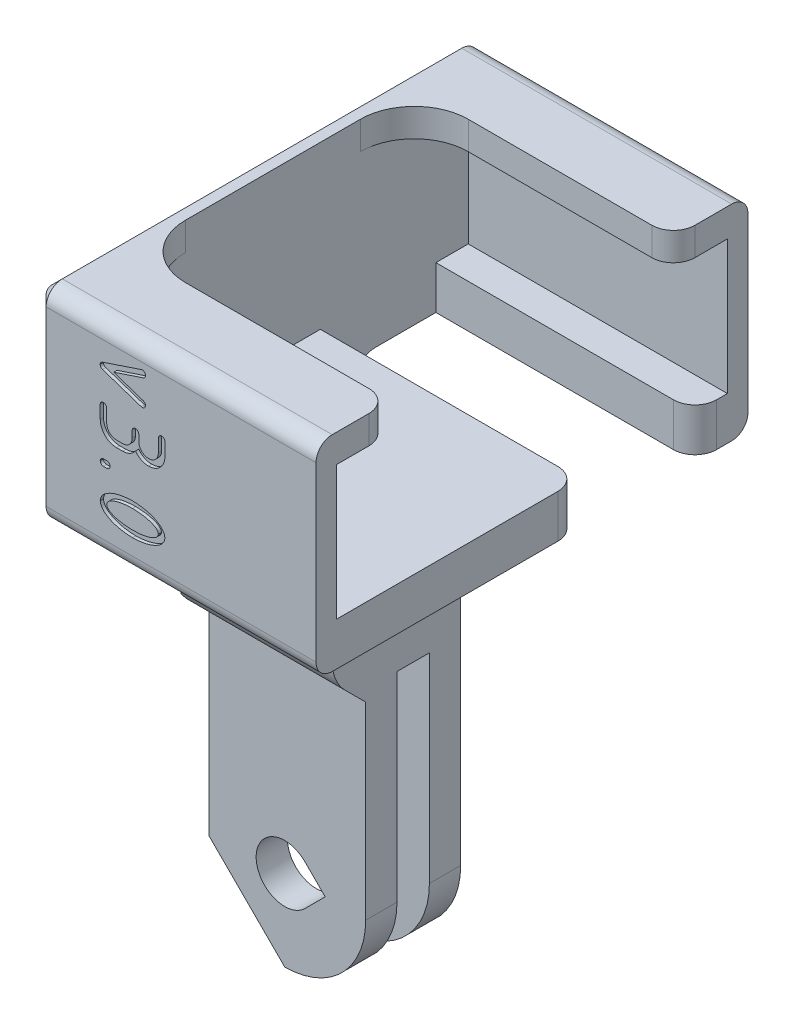
from build123d import *

# Parameters (mm, degrees)
SKETCH1_R                 = 2.65
BOSS_FINGERS_DEPTH        = 7.5
SKETCH2_W                 = 3
SKETCH2_H                 = 25
CUT_FINGERS_DEPTH         = 16
CUT_OVERHANG_DEPTH        = 12.9
CHAMF_GP_WEB_SIZE         = 1
CUT_GOPRO_TEARDROP_DEPTH  = 12.9
CHAMF_GP_BASE_SIZE        = 0.5
SKETCH3_W                 = 40
SKETCH3_H                 = 19
BOSS_BLOCK_DEPTH          = 26
FILLET5_R                 = 2
CUT_CAMERA_POCKET_DEPTH   = 24
SKETCH5_W                 = 24
SKETCH5_H                 = 10.7
CUT_CABLE_EXIT_DEPTH      = 15
CUT_CABLE_EXIT_DEPTH_BACK = 4
FILLET_OUTSIDE_VERT_R     = 1.5
FILLET_CAM_TOP_R          = 2
CHAMF_CAM_BASE_SIZE       = 1
FILLET_CAM_FRONT_R        = 5
FILLET6_R                 = 4
VERSION_NUMBER_DEPTH      = 0.3


with BuildPart() as part:
    # Sketch1 → boss fingers (new body, symmetric)
    with BuildSketch(Plane.XY):
        with BuildLine():
            Line((-7.5, 0), (-7.5, 32.5))
            Line((-7.5, 32.5), (7.5, 32.5))
            Line((7.5, 32.5), (7.5, 0))
            ThreePointArc((7.5, 0), (0, -7.5), (-7.5, 0))
        make_face()
        Circle(SKETCH1_R, mode=Mode.SUBTRACT)
    extrude(amount=BOSS_FINGERS_DEPTH, both=True)

    # Sketch2 → cut fingers (cut, through all)
    with BuildSketch(Plane.ZY.offset(7.5)):
        Polygon((-7.5, -7.5), (-4.4, -7.5), (-4.4, 17.5), (-7.5, 20.6), (-7.5, 17.5), align=None)
        with Locations((0, 5)):
            Rectangle(SKETCH2_W, SKETCH2_H)
        Polygon((4.4, -7.5), (7.5, -7.5), (7.5, 17.5), (7.5, 20.6), (4.4, 17.5), align=None)
    extrude(amount=-CUT_FINGERS_DEPTH, mode=Mode.SUBTRACT)

    # Sketch6 → cut overhang (cut, through all)
    with BuildSketch(Plane.XY.offset(4.4)):
        Polygon((-7.5, 0), (0, -7.5), (-7.5, -7.5), align=None)
    extrude(amount=-CUT_OVERHANG_DEPTH, mode=Mode.SUBTRACT)

    # chamf_gp_web
    chamf_gp_web_edges = [part.edges().sort_by_distance(p)[0] for p in [
        (7.5, 17.5, 0),
        (-7.5, 17.5, 0),
    ]]
    chamfer(chamf_gp_web_edges, length=CHAMF_GP_WEB_SIZE)

    # Sketch7 → cut_GoPro_tearDrop (cut, through all)
    with BuildSketch(Plane.XY.offset(4.4)):
        with BuildLine():
            Line((1.87383297, 1.87383297), (3.74766594, 0))
            Line((3.74766594, 0), (1.87383297, -1.87383297))
            ThreePointArc((1.87383297, -1.87383297), (-2.65, 0), (1.87383297, 1.87383297))
        make_face()
    extrude(amount=-CUT_GOPRO_TEARDROP_DEPTH, mode=Mode.SUBTRACT)

    # chamf_gp_base
    chamf_gp_base_edges = [part.edges().sort_by_distance(p)[0] for p in [
        (-7.5, 8.75, -4.4),
        (-7.5, 19.05, -5.95),
        (-7.5, 9.25, 1.5),
        (-7.5, 9.25, -1.5),
        (-7.5, 19.05, 5.95),
        (-7.5, 8.75, 4.4),
    ]]
    chamfer(chamf_gp_base_edges, length=CHAMF_GP_BASE_SIZE)

    # Sketch3 → boss block (add)
    with BuildSketch(Plane.ZY.offset(7.5)):
        with Locations((0, 42)):
            Rectangle(SKETCH3_W, SKETCH3_H)
    extrude(amount=-BOSS_BLOCK_DEPTH)

    # Fillet5
    fillet5_edges = [part.edges().sort_by_distance(p)[0] for p in [
        (0, 32.5, 7.5),
        (0, 32.5, -7.5),
        (7.5, 32.5, 0),
    ]]
    fillet(fillet5_edges, radius=FILLET5_R)

    # Sketch4 → cut camera pocket (cut)
    with BuildSketch(Plane(origin=(18.5, 0, 0), x_dir=(0, 0, -1), z_dir=(1, 0, 0))):
        Polygon((-18.1, 36.5), (18.1, 36.5), (18.1, 48.9), (13.1, 48.9), (13.1, 51.5), (-13.1, 51.5), (-13.1, 48.9), (-18.1, 48.9), align=None)
    extrude(amount=-CUT_CAMERA_POCKET_DEPTH, mode=Mode.SUBTRACT)

    # Sketch5 → cut cable exit (cut, two sides)
    with BuildSketch(Plane.XZ.offset(-32.5)) as cut_cable_exit_sk:
        with Locations((6.5, -9.75)):
            Rectangle(SKETCH5_W, SKETCH5_H)
    extrude(amount=CUT_CABLE_EXIT_DEPTH, mode=Mode.SUBTRACT)
    extrude(cut_cable_exit_sk.sketch, amount=-CUT_CABLE_EXIT_DEPTH_BACK, mode=Mode.SUBTRACT)

    # fillet outside vert
    fillet_outside_vert_edges = [part.edges().sort_by_distance(p)[0] for p in [
        (5.5, 32.5, -20),
        (5.5, 51.5, -20),
        (5.5, 51.5, 20),
        (5.5, 32.5, 20),
    ]]
    fillet(fillet_outside_vert_edges, radius=FILLET_OUTSIDE_VERT_R)

    # fillet_cam_top
    fillet_cam_top_edges = [part.edges().sort_by_distance(p)[0] for p in [
        (18.5, 50.2, 13.1),
        (18.5, 50.2, -13.1),
        (18.5, 34.5, -4.4),
        (18.5, 34.5, -15.1),
    ]]
    fillet(fillet_cam_top_edges, radius=FILLET_CAM_TOP_R)

    # chamf_cam_base
    chamf_cam_base_edges = [part.edges().sort_by_distance(p)[0] for p in [
        (-7.5, 32.5, 14),
        (-7.5, 32.939339828, 19.560660172),
        (-7.5, 42, 20),
        (-7.5, 51.060660172, 19.560660172),
        (-7.5, 51.5, 0),
        (-7.5, 32.5, -14),
        (-7.5, 51.060660172, -19.560660172),
        (-7.5, 32.939339828, -19.560660172),
        (-7.5, 42, -20),
        (-7.5, 25.903553391, 7.5),
        (-7.5, 31.914213562, 8.085786438),
        (-7.5, 25.903553391, -7.5),
        (-7.5, 31.914213562, -8.085786438),
    ]]
    chamfer(chamf_cam_base_edges, length=CHAMF_CAM_BASE_SIZE)

    # fillet_cam_front
    fillet_cam_front_edges = [part.edges().sort_by_distance(p)[0] for p in [
        (-5.5, 50.2, 13.1),
        (-5.5, 50.2, -13.1),
    ]]
    fillet(fillet_cam_front_edges, radius=FILLET_CAM_FRONT_R)

    # Fillet6
    fillet6_edges = [part.edges().sort_by_distance(p)[0] for p in [
        (0.5, 20.6, 7.5),
        (-6, 20.6, -7.5),
    ]]
    fillet(fillet6_edges, radius=FILLET6_R)

    # Sketch9 → version Number (cut)
    with BuildSketch(Plane.XY.offset(20)):
        with BuildLine():
            add(Edge.make_bspline(
                [(2.415134337, 49.401512481), (2.395720188, 49.398760447), (2.358182422, 49.393439317), (2.322234212, 49.381415148), (2.304878049, 49.375609756)],
                knots=[0, 0, 0, 0, 5.8684e-05, 0.000113467, 0.000113467, 0.000113467, 0.000113467], degree=3))
            Line((2.304878049, 49.375609756), (-1.27648509, 48.179249238))
            add(Edge.make_bspline(
                [(-1.27648509, 48.179249238), (-1.307862001, 48.165676126), (-1.367432677, 48.139906877), (-1.436447035, 48.072124842), (-1.483512064, 47.988320726), (-1.491950086, 47.924616718), (-1.496341463, 47.891463415)],
                knots=[0, 0, 0, 0, 0.000101745, 0.000193167, 0.00028485, 0.000384343, 0.000384343, 0.000384343, 0.000384343], degree=3))
            add(Edge.make_bspline(
                [(-1.496341463, 47.891463415), (-1.492026061, 47.856700004), (-1.483827687, 47.790656708), (-1.437212007, 47.703901075), (-1.367675055, 47.635729705), (-1.308089528, 47.61069493), (-1.276829268, 47.597560976)],
                knots=[0, 0, 0, 0, 0.000104281, 0.000198112, 0.000289535, 0.00039043, 0.00039043, 0.00039043, 0.00039043], degree=3))
            Line((-1.276829268, 47.597560976), (2.305815311, 46.400645484))
            add(Edge.make_bspline(
                [(2.305815311, 46.400645484), (2.322902999, 46.396290852), (2.358646107, 46.387182067), (2.395433619, 46.38438612), (2.414634146, 46.382926829)],
                knots=[0, 0, 0, 0, 5.2797e-05, 0.000110437, 0.000110437, 0.000110437, 0.000110437], degree=3))
            add(Edge.make_bspline(
                [(2.414634146, 46.382926829), (2.434704417, 46.384550212), (2.473547055, 46.387691996), (2.528774193, 46.405992393), (2.579700109, 46.432409078), (2.623181543, 46.470925496), (2.65989461, 46.516201522), (2.688878622, 46.567309489), (2.70443947, 46.625593056), (2.707942086, 46.665775042), (2.709756098, 46.686585366)],
                knots=[0, 0, 0, 0, 6.0202e-05, 0.000116512, 0.000173255, 0.000231191, 0.000289282, 0.000347678, 0.000405973, 0.000468597, 0.000468597, 0.000468597, 0.000468597], degree=3))
            add(Edge.make_bspline(
                [(2.709756098, 46.686585366), (2.705236337, 46.719663238), (2.696577868, 46.783030249), (2.651299669, 46.867974229), (2.581102395, 46.93461945), (2.521414738, 46.959944938), (2.490243902, 46.973170732)],
                knots=[0, 0, 0, 0, 9.9493e-05, 0.000190598, 0.000282903, 0.000383799, 0.000383799, 0.000383799, 0.000383799], degree=3))
            Line((2.490243902, 46.973170732), (-0.242158918, 47.892649581))
            Line((-0.242158918, 47.892649581), (2.49081674, 48.803024962))
            add(Edge.make_bspline(
                [(2.49081674, 48.803024962), (2.521841379, 48.815994795), (2.581729444, 48.841030966), (2.651719343, 48.909232006), (2.69693607, 48.997107423), (2.705326817, 49.062854577), (2.709756098, 49.097560976)],
                knots=[0, 0, 0, 0, 0.000100122, 0.000193269, 0.000286536, 0.000390816, 0.000390816, 0.000390816, 0.000390816], degree=3))
            add(Edge.make_bspline(
                [(2.709756098, 49.097560976), (2.707858675, 49.117537426), (2.704123954, 49.156857313), (2.689241905, 49.214204567), (2.659155527, 49.264609085), (2.62332612, 49.310800162), (2.579728964, 49.350341084), (2.529104018, 49.378369641), (2.473508746, 49.396379863), (2.434691366, 49.399570755), (2.415134337, 49.401512481)],
                knots=[0, 0, 0, 0, 6.0202e-05, 0.000118497, 0.000175827, 0.00023487, 0.000293609, 0.000350939, 0.000407248, 0.000467451, 0.000467451, 0.000467451, 0.000467451], degree=3))
        make_face()
        with BuildLine():
            add(Edge.make_bspline(
                [(1.474589129, 43.478576362), (1.470315732, 43.416264115), (1.462036765, 43.295544905), (1.41169664, 43.123326501), (1.331711879, 42.968438905), (1.222078556, 42.834282848), (1.090893618, 42.722284471), (0.938558934, 42.640964916), (0.770123745, 42.587426145), (0.651223726, 42.579615549), (0.590243902, 42.575609756)],
                knots=[0, 0, 0, 0, 0.000186936, 0.000362155, 0.000533972, 0.000706528, 0.000878756, 0.001047912, 0.001221495, 0.001404247, 0.001404247, 0.001404247, 0.001404247], degree=3))
            Line((0.590243902, 42.575609756), (0.004306402, 42.576630383))
            add(Edge.make_bspline(
                [(0.004306402, 42.576630383), (-0.056905974, 42.580175872), (-0.176088647, 42.587079066), (-0.344944107, 42.641257771), (-0.498352968, 42.722498666), (-0.631560546, 42.834237513), (-0.744197403, 42.967629047), (-0.823422135, 43.123633343), (-0.875870632, 43.295107157), (-0.883748251, 43.415864204), (-0.887804878, 43.47804878)],
                knots=[0, 0, 0, 0, 0.00018329, 0.000356873, 0.000527103, 0.000701203, 0.000875303, 0.00104712, 0.001222683, 0.001409073, 0.001409073, 0.001409073, 0.001409073], degree=3))
            Line((-0.887804878, 43.47804878), (-0.887804878, 44.683980802))
            add(Edge.make_bspline(
                [(-0.887804878, 44.683980802), (-0.888983836, 44.704506454), (-0.891310312, 44.745010382), (-0.909416357, 44.802145309), (-0.934644364, 44.855228582), (-0.972159639, 44.899698839), (-1.015370497, 44.938345289), (-1.066686254, 44.964932705), (-1.123148146, 44.983413948), (-1.16325411, 44.985499137), (-1.184146341, 44.986585366)],
                knots=[0, 0, 0, 0, 6.1444e-05, 0.00012125, 0.000178515, 0.000236606, 0.000294542, 0.000351286, 0.000408758, 0.000471251, 0.000471251, 0.000471251, 0.000471251], degree=3))
            add(Edge.make_bspline(
                [(-1.184146341, 44.986585366), (-1.205015303, 44.985410082), (-1.24585578, 44.983110055), (-1.303682343, 44.965216872), (-1.356507249, 44.938367975), (-1.40098506, 44.899765548), (-1.439587487, 44.855287737), (-1.466436384, 44.802462831), (-1.484329567, 44.744636268), (-1.486629594, 44.703795791), (-1.487804878, 44.682926829)],
                knots=[0, 0, 0, 0, 6.2493e-05, 0.000122299, 0.00018012, 0.000238986, 0.000297852, 0.000355673, 0.000415479, 0.000477972, 0.000477972, 0.000477972, 0.000477972], degree=3))
            Line((-1.487804878, 44.682926829), (-1.487804878, 43.478576362))
            add(Edge.make_bspline(
                [(-1.487804878, 43.478576362), (-1.485571919, 43.425873715), (-1.481195898, 43.322590182), (-1.4573567, 43.171320701), (-1.420809157, 43.02727717), (-1.372009068, 42.889970471), (-1.310443042, 42.759831996), (-1.23696974, 42.635820598), (-1.150219905, 42.518278789), (-1.050311901, 42.409883287), (-0.942765922, 42.309498435), (-0.826070384, 42.222936651), (-0.703679882, 42.148098989), (-0.575250612, 42.085477195), (-0.440012651, 42.036189785), (-0.29801823, 42.001497853), (-0.149526939, 41.977565974), (-0.04805806, 41.972231213), (0.003658537, 41.969512195)],
                knots=[0, 0, 0, 0, 0.000158146, 0.000309925, 0.000458405, 0.00060344, 0.000746368, 0.000889633, 0.001035246, 0.001183726, 0.001331308, 0.001475942, 0.001618792, 0.001761146, 0.001903886, 0.002049703, 0.002199072, 0.002354339, 0.002354339, 0.002354339, 0.002354339], degree=3))
            Line((0.003658537, 41.969512195), (0.590786966, 41.969713462))
            add(Edge.make_bspline(
                [(0.590786966, 41.969713462), (0.64929338, 41.971323554), (0.765273358, 41.974515313), (0.935511249, 42.006949251), (1.100323809, 42.055193916), (1.257636983, 42.124188433), (1.407082727, 42.209680303), (1.542075635, 42.316767676), (1.6693408, 42.435928497), (1.740646696, 42.528590505), (1.776829268, 42.575609756)],
                knots=[0, 0, 0, 0, 0.000175327, 0.000347559, 0.000518099, 0.0006896, 0.000861742, 0.001032982, 0.001205482, 0.001383183, 0.001383183, 0.001383183, 0.001383183], degree=3))
            add(Edge.make_bspline(
                [(1.776829268, 42.575609756), (1.814245122, 42.528568765), (1.888063061, 42.435761339), (2.018991446, 42.316698573), (2.157655963, 42.209574999), (2.310465967, 42.124453463), (2.470433327, 42.055137306), (2.637695471, 42.006943212), (2.81013677, 41.974607482), (2.927495003, 41.971218541), (2.986585366, 41.969512195)],
                knots=[0, 0, 0, 0, 0.000180034, 0.00035519, 0.000529337, 0.00070465, 0.000878391, 0.00105127, 0.001225903, 0.001403001, 0.001403001, 0.001403001, 0.001403001], degree=3))
            add(Edge.make_bspline(
                [(2.986585366, 41.969512195), (3.039112053, 41.972247936), (3.142594922, 41.977637621), (3.294318301, 42.001529364), (3.439618593, 42.035984229), (3.577648753, 42.08546548), (3.708475099, 42.148115978), (3.833194205, 42.222541667), (3.951186475, 42.309566265), (4.060091921, 42.409433458), (4.159889412, 42.518673507), (4.247892303, 42.635765844), (4.322793199, 42.759508365), (4.384137896, 42.890006969), (4.43302241, 43.027267086), (4.469547574, 43.171323464), (4.493361833, 43.322415752), (4.497759607, 43.425522354), (4.5, 43.47804878)],
                knots=[0, 0, 0, 0, 0.000157699, 0.000310684, 0.000460053, 0.000605088, 0.00074964, 0.000894577, 0.00104019, 0.001188671, 0.001337151, 0.001483492, 0.001627384, 0.001770312, 0.001915347, 0.002063827, 0.002215606, 0.002373226, 0.002373226, 0.002373226, 0.002373226], degree=3))
            Line((4.5, 43.47804878), (4.501017054, 44.683980802))
            add(Edge.make_bspline(
                [(4.501017054, 44.683980802), (4.499383612, 44.70448468), (4.49616311, 44.744910218), (4.478699841, 44.802469889), (4.451764196, 44.855285835), (4.413185156, 44.899766062), (4.368701067, 44.93836784), (4.315877823, 44.965216909), (4.258050806, 44.983110045), (4.217210393, 44.985410078), (4.196341463, 44.986585366)],
                knots=[0, 0, 0, 0, 6.1554e-05, 0.00012136, 0.00017918, 0.000238046, 0.000296912, 0.000354733, 0.000414539, 0.000477032, 0.000477032, 0.000477032, 0.000477032], degree=3))
            add(Edge.make_bspline(
                [(4.196341463, 44.986585366), (4.175458213, 44.985460609), (4.134979989, 44.98328048), (4.077703305, 44.964944251), (4.025192504, 44.938393785), (3.9807243, 44.899758577), (3.942119294, 44.855289565), (3.91527108, 44.802462329), (3.897377711, 44.744636402), (3.89507771, 44.703795836), (3.893902439, 44.682926829)],
                knots=[0, 0, 0, 0, 6.2493e-05, 0.000121131, 0.000178952, 0.000237818, 0.000296684, 0.000354505, 0.000414311, 0.000476804, 0.000476804, 0.000476804, 0.000476804], degree=3))
            Line((3.893902439, 44.682926829), (3.894100133, 43.478576362))
            add(Edge.make_bspline(
                [(3.894100133, 43.478576362), (3.890084815, 43.41618687), (3.882290908, 43.295086147), (3.828201252, 43.123538898), (3.747809565, 42.967533071), (3.63391885, 42.834210279), (3.499313579, 42.72212263), (3.343286016, 42.640947802), (3.170885256, 42.587302773), (3.049189008, 42.579581682), (2.986585366, 42.575609756)],
                knots=[0, 0, 0, 0, 0.000186935, 0.00036285, 0.000535233, 0.000710113, 0.000885154, 0.001057537, 0.001234619, 0.001422222, 0.001422222, 0.001422222, 0.001422222], degree=3))
            add(Edge.make_bspline(
                [(2.986585366, 42.575609756), (2.924805583, 42.579626749), (2.804336336, 42.587459798), (2.633403589, 42.640838916), (2.478468545, 42.722886597), (2.34282528, 42.833672247), (2.22932474, 42.967939333), (2.147044832, 43.123148565), (2.09371551, 43.295035063), (2.084982237, 43.415865449), (2.080487805, 43.47804878)],
                knots=[0, 0, 0, 0, 0.000185177, 0.000361092, 0.000532397, 0.000708383, 0.000883263, 0.001056219, 0.001232134, 0.001418655, 0.001418655, 0.001418655, 0.001418655], degree=3))
            Line((2.080487805, 43.47804878), (2.08150605, 44.077063881))
            add(Edge.make_bspline(
                [(2.08150605, 44.077063881), (2.079944528, 44.09785837), (2.076914863, 44.138203818), (2.058912245, 44.195474759), (2.032278259, 44.247974846), (1.993666443, 44.292452651), (1.949188454, 44.331030164), (1.89637361, 44.357978146), (1.838463169, 44.375495718), (1.797686778, 44.378798434), (1.776829268, 44.380487805)],
                knots=[0, 0, 0, 0, 6.2368e-05, 0.000121006, 0.000178827, 0.000237693, 0.000296559, 0.000354379, 0.000414185, 0.000476809, 0.000476809, 0.000476809, 0.000476809], degree=3))
            add(Edge.make_bspline(
                [(1.776829268, 44.380487805), (1.755957494, 44.378848199), (1.715542405, 44.375673345), (1.658183171, 44.35770481), (1.60568077, 44.331056113), (1.561218458, 44.292445169), (1.522581451, 44.247978559), (1.496031459, 44.195467337), (1.477695103, 44.138190767), (1.475514992, 44.097712527), (1.474390244, 44.076829268)],
                knots=[0, 0, 0, 0, 6.2624e-05, 0.000121262, 0.000179083, 0.000237949, 0.000296815, 0.000354636, 0.000413274, 0.000475767, 0.000475767, 0.000475767, 0.000475767], degree=3))
            Line((1.474390244, 44.076829268), (1.474589129, 43.478576362))
        make_face()
        with BuildLine():
            add(Edge.make_bspline(
                [(-1.18091654, 40.469312119), (-1.202037575, 40.467723133), (-1.243086471, 40.464634927), (-1.301308272, 40.447054369), (-1.354134815, 40.419670623), (-1.399821189, 40.381973132), (-1.438113219, 40.33660591), (-1.46645412, 40.284872116), (-1.484405761, 40.227162271), (-1.486648051, 40.186718919), (-1.487804878, 40.165853659)],
                knots=[0, 0, 0, 0, 6.3387e-05, 0.000123193, 0.000181013, 0.000240819, 0.000299685, 0.000358082, 0.00041672, 0.000479213, 0.000479213, 0.000479213, 0.000479213], degree=3))
            add(Edge.make_bspline(
                [(-1.487804878, 40.165853659), (-1.486597541, 40.145002661), (-1.484234787, 40.104197339), (-1.466735835, 40.045932895), (-1.438088313, 39.993887773), (-1.399827539, 39.948517388), (-1.354134941, 39.910800234), (-1.301301814, 39.883496906), (-1.243401148, 39.865688233), (-1.202571, 39.863376426), (-1.181707317, 39.862195122)],
                knots=[0, 0, 0, 0, 6.2493e-05, 0.000122299, 0.000180696, 0.000239562, 0.000299368, 0.000357188, 0.000416994, 0.000479488, 0.000479488, 0.000479488, 0.000479488], degree=3))
            Line((-1.181707317, 39.862195122), (-0.882552877, 39.862395198))
            add(Edge.make_bspline(
                [(-0.882552877, 39.862395198), (-0.860991539, 39.863459145), (-0.819056564, 39.865528432), (-0.759795808, 39.883606953), (-0.705963463, 39.910096603), (-0.661148124, 39.948651555), (-0.62395108, 39.993920408), (-0.596911483, 40.046263706), (-0.579102882, 40.104158615), (-0.576791065, 40.144989565), (-0.575609756, 40.165853659)],
                knots=[0, 0, 0, 0, 6.453e-05, 0.000125506, 0.00018441, 0.000243276, 0.000301366, 0.000359187, 0.000418993, 0.000481486, 0.000481486, 0.000481486, 0.000481486], degree=3))
            add(Edge.make_bspline(
                [(-0.575609756, 40.165853659), (-0.57674053, 40.18673204), (-0.578932321, 40.227200826), (-0.597185594, 40.284544642), (-0.623925834, 40.336574492), (-0.661154919, 40.381835118), (-0.705961949, 40.420388468), (-0.759795036, 40.446893093), (-0.819187154, 40.464948364), (-0.861240958, 40.46715486), (-0.882926829, 40.468292683)],
                knots=[0, 0, 0, 0, 6.2493e-05, 0.000121131, 0.000178952, 0.000237043, 0.000295908, 0.000354812, 0.000415788, 0.000480709, 0.000480709, 0.000480709, 0.000480709], degree=3))
            Line((-0.882926829, 40.468292683), (-1.18091654, 40.469312119))
        make_face()
        with BuildLine():
            add(Edge.make_bspline(
                [(1.503248857, 38.440043826), (1.39968553, 38.436886616), (1.196669366, 38.430697507), (0.898940707, 38.40734525), (0.614275214, 38.372780768), (0.343268605, 38.323656024), (0.085206813, 38.263418279), (-0.159354025, 38.188504508), (-0.391323316, 38.102303674), (-0.60833232, 38.004525938), (-0.805899448, 37.89726597), (-0.980346859, 37.782943983), (-1.128941442, 37.662135606), (-1.253139331, 37.53563872), (-1.352039234, 37.402720997), (-1.423985332, 37.262154256), (-1.472483048, 37.115979421), (-1.482707874, 37.014981104), (-1.487804878, 36.964634146)],
                knots=[0, 0, 0, 0, 0.000310797, 0.000609259, 0.000895598, 0.001170689, 0.001435132, 0.001690127, 0.001937484, 0.002177086, 0.002403567, 0.002611243, 0.002801901, 0.002976972, 0.003141859, 0.003296756, 0.003449097, 0.003600523, 0.003600523, 0.003600523, 0.003600523], degree=3))
            add(Edge.make_bspline(
                [(-1.487804878, 36.964634146), (-1.482760694, 36.913865586), (-1.472681995, 36.812425787), (-1.423661664, 36.665657658), (-1.35248361, 36.524264361), (-1.252707536, 36.391172327), (-1.129377218, 36.263489526), (-0.980631913, 36.142595244), (-0.805508431, 36.029758769), (-0.608364374, 35.922277271), (-0.39154518, 35.82433728), (-0.159308437, 35.739518032), (0.085427514, 35.66623936), (0.343100877, 35.605129869), (0.614432883, 35.558159628), (0.898918278, 35.523071967), (1.196384819, 35.499590962), (1.399144708, 35.494206489), (1.502439024, 35.491463415)],
                knots=[0, 0, 0, 0, 0.000152634, 0.000304975, 0.000460959, 0.000625846, 0.000801794, 0.000992451, 0.001199456, 0.001425938, 0.00166554, 0.001912473, 0.002167114, 0.002431557, 0.002706435, 0.002992774, 0.003291235, 0.003601186, 0.003601186, 0.003601186, 0.003601186], degree=3))
            add(Edge.make_bspline(
                [(1.502439024, 35.491463415), (1.606545794, 35.494203425), (1.810523452, 35.499571961), (2.109221283, 35.522979252), (2.394488696, 35.558283243), (2.666656511, 35.605099233), (2.925509408, 35.666324044), (3.170857417, 35.739025657), (3.402817753, 35.824644212), (3.619335683, 35.922260794), (3.816542609, 36.02969186), (3.991670735, 36.143013582), (4.141506807, 36.26307321), (4.264865637, 36.391217856), (4.364687803, 36.524253205), (4.435854486, 36.665660487), (4.484877687, 36.812425085), (4.494956006, 36.913865352), (4.5, 36.964634146)],
                knots=[0, 0, 0, 0, 0.000312388, 0.000612066, 0.000898404, 0.001174483, 0.001440113, 0.001695923, 0.001941711, 0.002181314, 0.002407795, 0.0026148, 0.002806403, 0.002982351, 0.003147238, 0.003303221, 0.003455563, 0.003608197, 0.003608197, 0.003608197, 0.003608197], degree=3))
            add(Edge.make_bspline(
                [(4.5, 36.964634146), (4.494903184, 37.014981336), (4.484678737, 37.115980118), (4.436178153, 37.262151428), (4.364243384, 37.40273209), (4.265297389, 37.535593179), (4.141068749, 37.662549561), (3.991384006, 37.78252326), (3.816933492, 37.897332652), (3.619304071, 38.004542991), (3.402593696, 38.101995123), (3.170908031, 38.189003791), (2.925728492, 38.263334548), (2.666489493, 38.323682147), (2.394645815, 38.37267132), (2.109196616, 38.407373334), (1.810530046, 38.430951994), (1.606548022, 38.436296595), (1.502439024, 38.43902439)],
                knots=[0, 0, 0, 0, 0.000151426, 0.000303767, 0.000458665, 0.000623551, 0.000798623, 0.000990226, 0.001197901, 0.001424383, 0.001663985, 0.0019102, 0.002166361, 0.002431991, 0.002708282, 0.002994621, 0.003294299, 0.003606687, 0.003606687, 0.003606687, 0.003606687], degree=3))
            Line((1.502439024, 38.43902439), (1.503248857, 38.440043826))
        make_face()
        with BuildLine():
            add(Edge.make_bspline(
                [(1.503248857, 37.833126905), (1.58633005, 37.831562083), (1.749203047, 37.828494394), (1.988096295, 37.814940729), (2.216318996, 37.794493794), (2.433559863, 37.766474623), (2.640459367, 37.731637605), (2.835982131, 37.687464062), (3.020968943, 37.637822227), (3.192979974, 37.581281911), (3.349391998, 37.518491895), (3.487884854, 37.451804962), (3.6068279, 37.381605497), (3.706205147, 37.3074496), (3.783982874, 37.227905607), (3.842116063, 37.144619419), (3.880722296, 37.056604415), (3.889543116, 36.995053245), (3.893902439, 36.964634146)],
                knots=[0, 0, 0, 0, 0.00024927, 0.00048867, 0.000717659, 0.000936537, 0.001145647, 0.001346837, 0.001537651, 0.001720061, 0.001889678, 0.002042939, 0.002180766, 0.002303453, 0.002413844, 0.002512955, 0.002606952, 0.002698797, 0.002698797, 0.002698797, 0.002698797], degree=3))
            add(Edge.make_bspline(
                [(3.893902439, 36.964634146), (3.889605946, 36.933785939), (3.880968898, 36.871773177), (3.841751949, 36.783274393), (3.784484069, 36.698958586), (3.705764017, 36.619506957), (3.607311618, 36.543784361), (3.487769558, 36.473990737), (3.349696698, 36.406788173), (3.192640988, 36.346001548), (3.021204263, 36.288617589), (2.835918753, 36.240667006), (2.640315211, 36.197898235), (2.433567784, 36.162811199), (2.216386642, 36.134381162), (1.988020721, 36.116015604), (1.748947119, 36.101802049), (1.58579433, 36.09899507), (1.502439024, 36.097560976)],
                knots=[0, 0, 0, 0, 9.3043e-05, 0.000187041, 0.00028716, 0.000397551, 0.000520981, 0.000658807, 0.000812068, 0.000981234, 0.001163644, 0.001354141, 0.001555069, 0.001764179, 0.001983056, 0.002211938, 0.002451339, 0.002701413, 0.002701413, 0.002701413, 0.002701413], degree=3))
            add(Edge.make_bspline(
                [(1.502439024, 36.097560976), (1.419490211, 36.098995897), (1.257149879, 36.101804204), (1.019293944, 36.116002164), (0.791748923, 36.134451922), (0.574973717, 36.162831565), (0.368594091, 36.197739837), (0.17345891, 36.240814195), (-0.011785728, 36.288815101), (-0.184114061, 36.345961015), (-0.342283221, 36.40692724), (-0.481227142, 36.473314855), (-0.600212199, 36.544129347), (-0.698530533, 36.619826183), (-0.77825188, 36.698943722), (-0.836908544, 36.782938693), (-0.876333042, 36.871681321), (-0.883996934, 36.933779523), (-0.887804878, 36.964634146)],
                knots=[0, 0, 0, 0, 0.000248855, 0.000487038, 0.000714705, 0.000933583, 0.001142693, 0.001342429, 0.001532926, 0.001716494, 0.001886794, 0.002041153, 0.002177934, 0.002301364, 0.002412608, 0.002513415, 0.002607412, 0.00270024, 0.00270024, 0.00270024, 0.00270024], degree=3))
            add(Edge.make_bspline(
                [(-0.887804878, 36.964634146), (-0.88393381, 36.995059808), (-0.876091479, 37.056698637), (-0.83727112, 37.144959866), (-0.777747881, 37.227911289), (-0.698974529, 37.307134911), (-0.599731874, 37.38126482), (-0.481342154, 37.452480392), (-0.341979338, 37.518349959), (-0.184451516, 37.581324745), (-0.011550595, 37.63762354), (0.173398214, 37.68731118), (0.368448146, 37.731798809), (0.574981943, 37.766453276), (0.791816997, 37.794424195), (1.019218334, 37.814940405), (1.25716053, 37.828561166), (1.419493812, 37.831450504), (1.503248857, 37.833126905)],
                knots=[0, 0, 0, 0, 9.1626e-05, 0.000185623, 0.00028543, 0.000396673, 0.00051936, 0.000656141, 0.0008105, 0.000981249, 0.001164817, 0.001355631, 0.001555631, 0.00176474, 0.001983618, 0.002211393, 0.002449576, 0.002698431, 0.002698431, 0.002698431, 0.002698431], degree=3))
        make_face(mode=Mode.SUBTRACT)
    extrude(amount=-VERSION_NUMBER_DEPTH, mode=Mode.SUBTRACT)


solid = part.part
